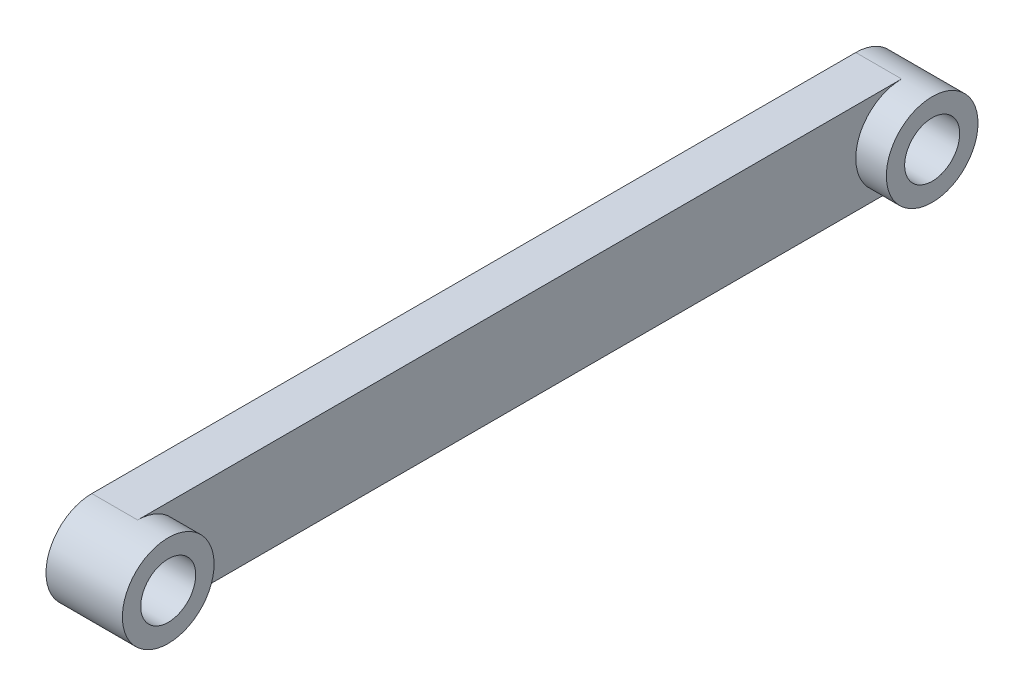
from build123d import *

# Parameters (mm, degrees)
SKETCH1_R           = 1.8
BOSS_EXTRUDE1_DEPTH = 3
SKETCH2_R           = 3
SKETCH2_R_2         = 1.8
BOSS_EXTRUDE2_DEPTH = 2


with BuildPart() as part:
    # Sketch1 → Boss-Extrude1 (new body)
    with BuildSketch(Plane(origin=(0, 0, 0), x_dir=(0, 0, -1), z_dir=(1, 0, 0))):
        with BuildLine():
            Line((-66.603258311, 3.562711266), (-16.603258311, 3.562711266))
            ThreePointArc((-16.603258311, 3.562711266), (-13.603258311, 6.562711266), (-16.603258311, 9.562711266))
            Line((-16.603258311, 9.562711266), (-66.603258311, 9.562711266))
            ThreePointArc((-66.603258311, 9.562711266), (-69.603258311, 6.562711266), (-66.603258311, 3.562711266))
        make_face()
        with Locations((-66.603258311, 6.562711266)):
            Circle(SKETCH1_R, mode=Mode.SUBTRACT)
        with Locations((-16.603258311, 6.562711266)):
            Circle(SKETCH1_R, mode=Mode.SUBTRACT)
    extrude(amount=BOSS_EXTRUDE1_DEPTH)

    # Sketch2 → Boss-Extrude2 (add)
    with BuildSketch(Plane(origin=(3, 0, 0), x_dir=(0, 0, -1), z_dir=(1, 0, 0))):
        with Locations((-66.603258311, 6.562711266)):
            Circle(SKETCH2_R)
        with Locations((-66.603258311, 6.562711266)):
            Circle(SKETCH2_R_2, mode=Mode.SUBTRACT)
        with Locations((-16.603258311, 6.562711266)):
            Circle(SKETCH2_R)
        with Locations((-16.603258311, 6.562711266)):
            Circle(SKETCH2_R_2, mode=Mode.SUBTRACT)
    extrude(amount=BOSS_EXTRUDE2_DEPTH)


solid = part.part
